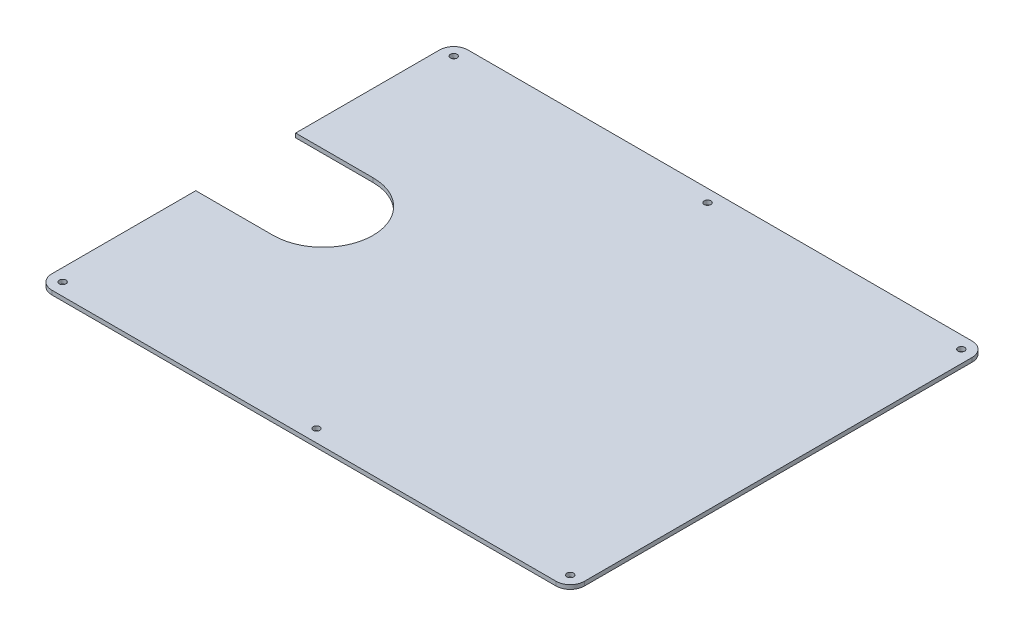
from build123d import *

# Parameters (mm, degrees)
CROQUIS1_R              = 4
SALIENTE_EXTRUIR1_DEPTH = 5
CORTAR_EXTRUIR2_DEPTH   = 6


with BuildPart() as part:
    # Croquis1 → Saliente-Extruir1 (new body)
    with BuildSketch(Plane(origin=(0, 0, 0), x_dir=(1, 0, 0), z_dir=(0, 1, 0))):
        with BuildLine():
            Line((-303, 250), (303, 250))
            ThreePointArc((303, 250), (315.02081528, 245.02081528), (320, 233))
            Line((320, 233), (320, -233))
            ThreePointArc((320, -233), (315.02081528, -245.02081528), (303, -250))
            Line((303, -250), (-303, -250))
            ThreePointArc((-303, -250), (-315.02081528, -245.02081528), (-320, -233))
            Line((-320, -233), (-320, 233))
            ThreePointArc((-320, 233), (-315.02081528, 245.02081528), (-303, 250))
        make_face()
        with Locations((0, 235)):
            Circle(CROQUIS1_R, mode=Mode.SUBTRACT)
        with Locations((305, 235)):
            Circle(CROQUIS1_R, mode=Mode.SUBTRACT)
        with Locations((-305, 235)):
            Circle(CROQUIS1_R, mode=Mode.SUBTRACT)
        with Locations((0, -235)):
            Circle(CROQUIS1_R, mode=Mode.SUBTRACT)
        with Locations((305, -235)):
            Circle(CROQUIS1_R, mode=Mode.SUBTRACT)
        with Locations((-305, -235)):
            Circle(CROQUIS1_R, mode=Mode.SUBTRACT)
    extrude(amount=SALIENTE_EXTRUIR1_DEPTH)

    # Croquis3 → Cortar-Extruir2 (cut, through all)
    with BuildSketch(Plane.XZ):
        with BuildLine():
            Line((-227, 60), (-320, 60))
            Line((-320, 60), (-320, -60))
            Line((-320, -60), (-227, -60))
            ThreePointArc((-227, -60), (-167, 0), (-227, 60))
        make_face()
    extrude(amount=-CORTAR_EXTRUIR2_DEPTH, mode=Mode.SUBTRACT)


solid = part.part
